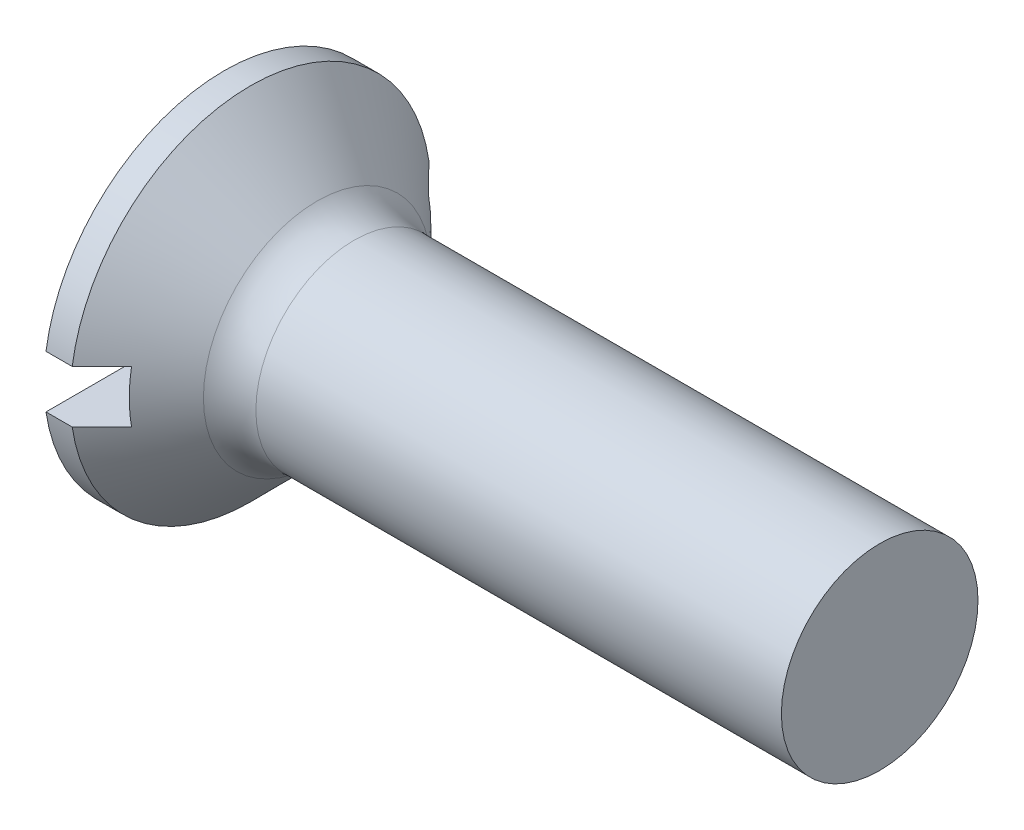
from build123d import *

# Parameters (mm, degrees)
FILLET1_R  = 0.8
SKETCH2_W  = 5.5
SKETCH2_H  = 0.8
SLOT_DEPTH = 0.85


with BuildPart() as part:
    # BodySke → Base-Revolve (revolve)
    with BuildSketch(Plane.XY):
        Polygon((0, 0), (0, 2.75), (0.4, 2.75), (1.65, 1.5), (10, 1.5), (10, 0), align=None)
    revolve(axis=Axis((-6.35, 0, 0), (1, 0, 0)))

    # Fillet1
    fillet1_edges = [part.edges().sort_by_distance(p)[0] for p in [
        (1.65, -1.5, 0),
    ]]
    fillet(fillet1_edges, radius=FILLET1_R)

    # Sketch2 → Slot (cut)
    with BuildSketch(Plane.ZY):
        Rectangle(SKETCH2_W, SKETCH2_H)
    extrude(amount=-SLOT_DEPTH, mode=Mode.SUBTRACT)


solid = part.part
